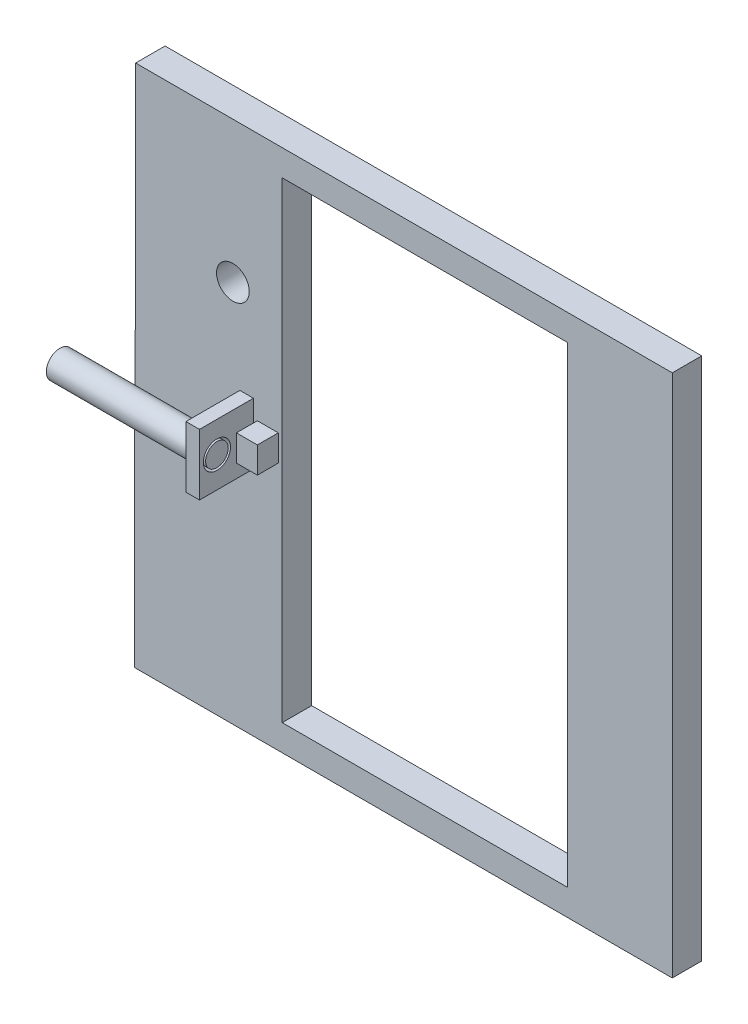
from build123d import *

# Parameters (mm, degrees)
SKETCH1_W                = 203.2
SKETCH1_H                = 254.254
SKETCH1_W_2              = 138.43
SKETCH1_H_2              = 228.9175
BOSS_EXTRUDE1_DEPTH      = 1.5875
BOSS_EXTRUDE1_DEPTH_BACK = 12.7
SKETCH2_W                = 10.16
SKETCH2_H                = 12.7
BOSS_EXTRUDE2_DEPTH      = 10.16
SKETCH3_W                = 15.24
SKETCH3_H                = 29.693732077
BOSS_EXTRUDE3_DEPTH      = 6.578885717
SKETCH5_W                = 6.578885717
SKETCH5_H                = 29.693732077
BOSS_EXTRUDE4_DEPTH      = 26.162
SKETCH6_R                = 6.604
BOSS_EXTRUDE6_DEPTH      = 76.2
SKETCH11_R               = 6.604
CUT_EXTRUDE3_DEPTH       = 5.842
SKETCH13_R               = 5.4991
BOSS_EXTRUDE7_DEPTH      = 5.842
SKETCH15_W               = 15.24
SKETCH15_H               = 29.693732077
BOSS_EXTRUDE8_DEPTH      = 50.8
SKETCH16_W               = 14.2875
SKETCH16_H               = 112.267770999
BOSS_EXTRUDE9_DEPTH      = 57.15
SKETCH17_W               = 14.2875
SKETCH17_H               = 112.292496924
BOSS_EXTRUDE10_DEPTH     = 57.658
SKETCH18_R               = 7.9375
CUT_EXTRUDE4_DEPTH       = 57.658


with BuildPart() as part:
    # Sketch1 → Boss-Extrude1 (new body, two sides)
    with BuildSketch(Plane.XY) as boss_extrude1_sk:
        with Locations((18.415, 0)):
            Rectangle(SKETCH1_W, SKETCH1_H)
        Rectangle(SKETCH1_W_2, SKETCH1_H_2, mode=Mode.SUBTRACT)
    extrude(amount=BOSS_EXTRUDE1_DEPTH)
    extrude(boss_extrude1_sk.sketch, amount=-BOSS_EXTRUDE1_DEPTH_BACK)

    # Sketch2 → Boss-Extrude2 (add)
    with BuildSketch(Plane.XY.offset(1.5875)):
        with Locations((-76.2, 0)):
            Rectangle(SKETCH2_W, SKETCH2_H)
    extrude(amount=BOSS_EXTRUDE2_DEPTH)

    # Sketch3 → Boss-Extrude3 (add)
    with BuildSketch(Plane.ZY.offset(83.185)):
        with Locations((-6.0325, 0.012362963)):
            Rectangle(SKETCH3_W, SKETCH3_H)
    extrude(amount=BOSS_EXTRUDE3_DEPTH)

    # Sketch5 → Boss-Extrude4 (add)
    with BuildSketch(Plane.XY.offset(1.5875)):
        with Locations((-86.474442858, 0.012362963)):
            Rectangle(SKETCH5_W, SKETCH5_H)
    extrude(amount=BOSS_EXTRUDE4_DEPTH)

    # Sketch6 → Boss-Extrude6 (add)
    with BuildSketch(Plane(origin=(-83.185, 0, 0), x_dir=(0, 0, -1), z_dir=(1, 0, 0))):
        with Locations((-19.291204972, 0)):
            Circle(SKETCH6_R)
    extrude(amount=-BOSS_EXTRUDE6_DEPTH)

    # Sketch11 → Cut-Extrude3 (cut)
    with BuildSketch(Plane(origin=(-83.185, 0, 0), x_dir=(0, 0, -1), z_dir=(1, 0, 0))):
        with Locations((-19.291204972, 0)):
            Circle(SKETCH11_R)
    extrude(amount=-CUT_EXTRUDE3_DEPTH, mode=Mode.SUBTRACT)

    # Sketch13 → Boss-Extrude7 (add)
    with BuildSketch(Plane(origin=(-89.027, 0, 0), x_dir=(0, 0, -1), z_dir=(1, 0, 0))):
        with Locations((-19.291204972, 0)):
            Circle(SKETCH13_R)
    extrude(amount=BOSS_EXTRUDE7_DEPTH)

    # Sketch15 → Boss-Extrude8 (add)
    with BuildSketch(Plane.ZY.offset(89.763885717)):
        with Locations((-6.0325, 0.012362963)):
            Rectangle(SKETCH15_W, SKETCH15_H)
    extrude(amount=BOSS_EXTRUDE8_DEPTH)

    # Sketch16 → Boss-Extrude9 (add)
    with BuildSketch(Plane.ZY.offset(83.185)):
        with Locations((-5.55625, 70.9931145)):
            Rectangle(SKETCH16_W, SKETCH16_H)
    extrude(amount=BOSS_EXTRUDE9_DEPTH)

    # Sketch17 → Boss-Extrude10 (add)
    with BuildSketch(Plane.ZY.offset(83.185)):
        with Locations((-5.55625, -70.980751538)):
            Rectangle(SKETCH17_W, SKETCH17_H)
    extrude(amount=BOSS_EXTRUDE10_DEPTH)

    # Sketch18 → Cut-Extrude4 (cut)
    with BuildSketch(Plane.XY.offset(1.5875)):
        with Locations((-93.141229835, 58.590088082)):
            Circle(SKETCH18_R)
    extrude(amount=-CUT_EXTRUDE4_DEPTH, mode=Mode.SUBTRACT)


solid = part.part
